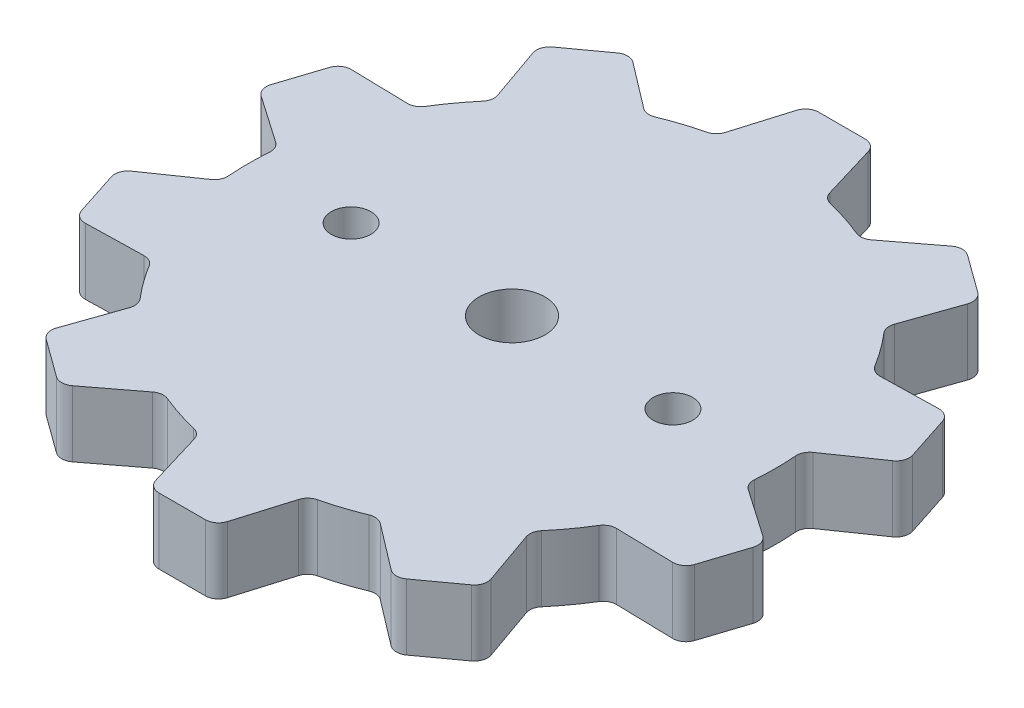
from build123d import *

# Parameters (mm, degrees)
SKETCH1_R             = 20
BOSS_EXTRUDE1_DEPTH   = 5
SKETCH2_R             = 2.5
CUT_EXTRUDE1_DEPTH    = 5
FILLET1_R             = 1
FILLET2_R             = 1
F_3_0MM_DOWEL_HOLE1_D = 3


with BuildPart() as part:
    # Sketch1 → Boss-Extrude1 (new body)
    with BuildSketch(Plane(origin=(0, 0, 0), x_dir=(1, 0, 0), z_dir=(0, 1, 0))):
        Circle(SKETCH1_R)
        with BuildLine():
            ThreePointArc((14.84307285, 13.404595793), (11.755705046, 16.180339887), (8.161766418, 18.258849058))
            ThreePointArc((8.161766418, 18.258849058), (6.180339888, 19.021130326), (4.129274464, 19.569085119))
            ThreePointArc((4.129274464, 19.569085119), (0, 20), (-4.129274464, 19.569085119))
            ThreePointArc((-4.129274464, 19.569085119), (-6.180339887, 19.021130326), (-8.161766418, 18.258849058))
            ThreePointArc((-8.161766418, 18.258849058), (-11.755705046, 16.180339888), (-14.84307285, 13.404595793))
            ThreePointArc((-14.84307285, 13.404595793), (-16.180339887, 11.755705046), (-17.335289937, 9.974353253))
            ThreePointArc((-17.335289937, 9.974353253), (-19.021130326, 6.180339888), (-19.887321904, 2.120006479))
            ThreePointArc((-19.887321904, 2.120006479), (-20, 0), (-19.887321904, -2.120006479))
            ThreePointArc((-19.887321904, -2.120006479), (-19.021130326, -6.180339887), (-17.335289937, -9.974353253))
            ThreePointArc((-17.335289937, -9.974353253), (-16.180339888, -11.755705046), (-14.84307285, -13.404595793))
            ThreePointArc((-14.84307285, -13.404595793), (-11.755705046, -16.180339887), (-8.161766418, -18.258849058))
            ThreePointArc((-8.161766418, -18.258849058), (-6.180339888, -19.021130326), (-4.129274464, -19.569085119))
            ThreePointArc((-4.129274464, -19.569085119), (0, -20), (4.129274464, -19.569085119))
            ThreePointArc((4.129274464, -19.569085119), (6.180339887, -19.021130326), (8.161766418, -18.258849058))
            ThreePointArc((8.161766418, -18.258849058), (11.755705046, -16.180339888), (14.84307285, -13.404595793))
            ThreePointArc((14.84307285, -13.404595793), (16.180339887, -11.755705046), (17.335289937, -9.974353253))
            ThreePointArc((17.335289937, -9.974353253), (19.021130326, -6.180339888), (19.887321904, -2.120006479))
            ThreePointArc((19.887321904, -2.120006479), (19.97181061, -1.061499391), (20, 0))
            ThreePointArc((20, 0), (19.97181061, 1.061499391), (19.887321904, 2.120006479))
            ThreePointArc((19.887321904, 2.120006479), (19.021130326, 6.180339887), (17.335289937, 9.974353253))
            ThreePointArc((17.335289937, 9.974353253), (16.180339888, 11.755705046), (14.84307285, 13.404595793))
        make_face()
        with BuildLine():
            ThreePointArc((-4.129274464, 19.569085119), (0, 20), (4.129274464, 19.569085119))
            Line((4.129274464, 19.569085119), (4, 20))
            Line((4, 20), (2.5, 25))
            Line((2.5, 25), (0, 25))
            Line((0, 25), (-2.5, 25))
            Line((-2.5, 25), (-4, 20))
            Line((-4, 20), (-4.129274464, 19.569085119))
        make_face()
        with BuildLine():
            Line((14.694631307, 20.225424859), (12.672088821, 21.69488799))
            Line((12.672088821, 21.69488799), (8.519637068, 18.531480897))
            Line((8.519637068, 18.531480897), (8.161766418, 18.258849058))
            ThreePointArc((8.161766418, 18.258849058), (11.755705046, 16.180339887), (14.84307285, 13.404595793))
            Line((14.84307285, 13.404595793), (14.991773023, 13.829198878))
            Line((14.991773023, 13.829198878), (16.717173793, 18.755961729))
            Line((16.717173793, 18.755961729), (14.694631307, 20.225424859))
        make_face()
        with BuildLine():
            Line((17.785062348, 9.984565953), (17.335289937, 9.974353253))
            ThreePointArc((17.335289937, 9.974353253), (19.021130326, 6.180339887), (19.887321904, 2.120006479))
            Line((19.887321904, 2.120006479), (20.257198303, 2.376113822))
            Line((20.257198303, 2.376113822), (24.548955393, 5.347783569))
            Line((24.548955393, 5.347783569), (23.776412907, 7.725424859))
            Line((23.776412907, 7.725424859), (23.003870421, 10.10306615))
            Line((23.003870421, 10.10306615), (17.785062348, 9.984565953))
        make_face()
        with BuildLine():
            Line((20.257198303, -2.376113822), (19.887321904, -2.120006479))
            ThreePointArc((19.887321904, -2.120006479), (19.021130326, -6.180339888), (17.335289937, -9.974353253))
            Line((17.335289937, -9.974353253), (17.785062348, -9.984565953))
            Line((17.785062348, -9.984565953), (23.003870421, -10.10306615))
            Line((23.003870421, -10.10306615), (23.776412907, -7.725424859))
            Line((23.776412907, -7.725424859), (24.548955393, -5.347783569))
            Line((24.548955393, -5.347783569), (20.257198303, -2.376113822))
        make_face()
        with BuildLine():
            ThreePointArc((-14.84307285, 13.404595793), (-11.755705046, 16.180339888), (-8.161766418, 18.258849058))
            Line((-8.161766418, 18.258849058), (-8.519637068, 18.531480897))
            Line((-8.519637068, 18.531480897), (-12.672088821, 21.69488799))
            Line((-12.672088821, 21.69488799), (-14.694631307, 20.225424859))
            Line((-14.694631307, 20.225424859), (-16.717173793, 18.755961729))
            Line((-16.717173793, 18.755961729), (-14.991773023, 13.829198878))
            Line((-14.991773023, 13.829198878), (-14.84307285, 13.404595793))
        make_face()
        with BuildLine():
            ThreePointArc((-19.887321904, 2.120006479), (-19.021130326, 6.180339888), (-17.335289937, 9.974353253))
            Line((-17.335289937, 9.974353253), (-17.785062348, 9.984565953))
            Line((-17.785062348, 9.984565953), (-23.003870421, 10.10306615))
            Line((-23.003870421, 10.10306615), (-23.776412907, 7.725424859))
            Line((-23.776412907, 7.725424859), (-24.548955393, 5.347783569))
            Line((-24.548955393, 5.347783569), (-20.257198303, 2.376113822))
            Line((-20.257198303, 2.376113822), (-19.887321904, 2.120006479))
        make_face()
        with BuildLine():
            ThreePointArc((-17.335289937, -9.974353253), (-19.021130326, -6.180339887), (-19.887321904, -2.120006479))
            Line((-19.887321904, -2.120006479), (-20.257198303, -2.376113822))
            Line((-20.257198303, -2.376113822), (-24.548955393, -5.347783569))
            Line((-24.548955393, -5.347783569), (-23.776412907, -7.725424859))
            Line((-23.776412907, -7.725424859), (-23.003870421, -10.10306615))
            Line((-23.003870421, -10.10306615), (-17.785062348, -9.984565953))
            Line((-17.785062348, -9.984565953), (-17.335289937, -9.974353253))
        make_face()
        with BuildLine():
            ThreePointArc((-8.161766418, -18.258849058), (-11.755705046, -16.180339887), (-14.84307285, -13.404595793))
            Line((-14.84307285, -13.404595793), (-14.991773023, -13.829198878))
            Line((-14.991773023, -13.829198878), (-16.717173793, -18.755961729))
            Line((-16.717173793, -18.755961729), (-14.694631307, -20.225424859))
            Line((-14.694631307, -20.225424859), (-12.672088821, -21.69488799))
            Line((-12.672088821, -21.69488799), (-8.519637068, -18.531480897))
            Line((-8.519637068, -18.531480897), (-8.161766418, -18.258849058))
        make_face()
        with BuildLine():
            Line((4, -20), (4.129274464, -19.569085119))
            ThreePointArc((4.129274464, -19.569085119), (0, -20), (-4.129274464, -19.569085119))
            Line((-4.129274464, -19.569085119), (-4, -20))
            Line((-4, -20), (-2.5, -25))
            Line((-2.5, -25), (0, -25))
            Line((0, -25), (2.5, -25))
            Line((2.5, -25), (4, -20))
        make_face()
        with BuildLine():
            Line((14.991773023, -13.829198878), (14.84307285, -13.404595793))
            ThreePointArc((14.84307285, -13.404595793), (11.755705046, -16.180339888), (8.161766418, -18.258849058))
            Line((8.161766418, -18.258849058), (8.519637068, -18.531480897))
            Line((8.519637068, -18.531480897), (12.672088821, -21.69488799))
            Line((12.672088821, -21.69488799), (14.694631307, -20.225424859))
            Line((14.694631307, -20.225424859), (16.717173793, -18.755961729))
            Line((16.717173793, -18.755961729), (14.991773023, -13.829198878))
        make_face()
    extrude(amount=BOSS_EXTRUDE1_DEPTH)

    # Sketch2 → Cut-Extrude1 (cut)
    with BuildSketch(Plane(origin=(0, 5, 0), x_dir=(1, 0, 0), z_dir=(0, 1, 0))):
        Circle(SKETCH2_R)
    extrude(amount=-CUT_EXTRUDE1_DEPTH, mode=Mode.SUBTRACT)

    # Fillet1
    fillet1_edges = [part.edges().sort_by_distance(p)[0] for p in [
        (-4.129274464, 2.5, 19.569085119),
        (-8.161766418, 2.5, 18.258849058),
        (-14.84307285, 2.5, 13.404595793),
        (-17.335289937, 2.5, 9.974353253),
        (-19.887321904, 2.5, 2.120006479),
        (-19.887321904, 2.5, -2.120006479),
        (-17.335289937, 2.5, -9.974353253),
        (-14.84307285, 2.5, -13.404595793),
        (-8.161766418, 2.5, -18.258849058),
        (-4.129274464, 2.5, -19.569085119),
        (4.129274464, 2.5, -19.569085119),
        (8.161766418, 2.5, -18.258849058),
        (14.84307285, 2.5, -13.404595793),
        (17.335289937, 2.5, -9.974353253),
        (19.887321904, 2.5, -2.120006479),
        (19.887321904, 2.5, 2.120006479),
        (17.335289937, 2.5, 9.974353253),
        (14.84307285, 2.5, 13.404595793),
        (8.161766418, 2.5, 18.258849058),
        (4.129274464, 2.5, 19.569085119),
    ]]
    fillet(fillet1_edges, radius=FILLET1_R)

    # Fillet2
    fillet2_edges = [part.edges().sort_by_distance(p)[0] for p in [
        (2.5, 2.5, 25),
        (-2.5, 2.5, 25),
        (-12.672088821, 2.5, 21.69488799),
        (-16.717173793, 2.5, 18.755961729),
        (-23.003870421, 2.5, 10.10306615),
        (-24.548955393, 2.5, 5.347783569),
        (-24.548955393, 2.5, -5.347783569),
        (-23.003870421, 2.5, -10.10306615),
        (-16.717173793, 2.5, -18.755961729),
        (-12.672088821, 2.5, -21.69488799),
        (-2.5, 2.5, -25),
        (2.5, 2.5, -25),
        (12.672088821, 2.5, -21.69488799),
        (16.717173793, 2.5, -18.755961729),
        (23.003870421, 2.5, -10.10306615),
        (24.548955393, 2.5, -5.347783569),
        (24.548955393, 2.5, 5.347783569),
        (23.003870421, 2.5, 10.10306615),
        (16.717173793, 2.5, 18.755961729),
        (12.672088821, 2.5, 21.69488799),
    ]]
    fillet(fillet2_edges, radius=FILLET2_R)

    # Ø3.0mm Dowel Hole1 (through all)
    with Locations(Plane(origin=(0, 5, 0), x_dir=(1, 0, 0), z_dir=(0, 1, 0))):
        with Locations((12.2, 0), (-12.2, 0)):
            Hole(F_3_0MM_DOWEL_HOLE1_D / 2)


solid = part.part
